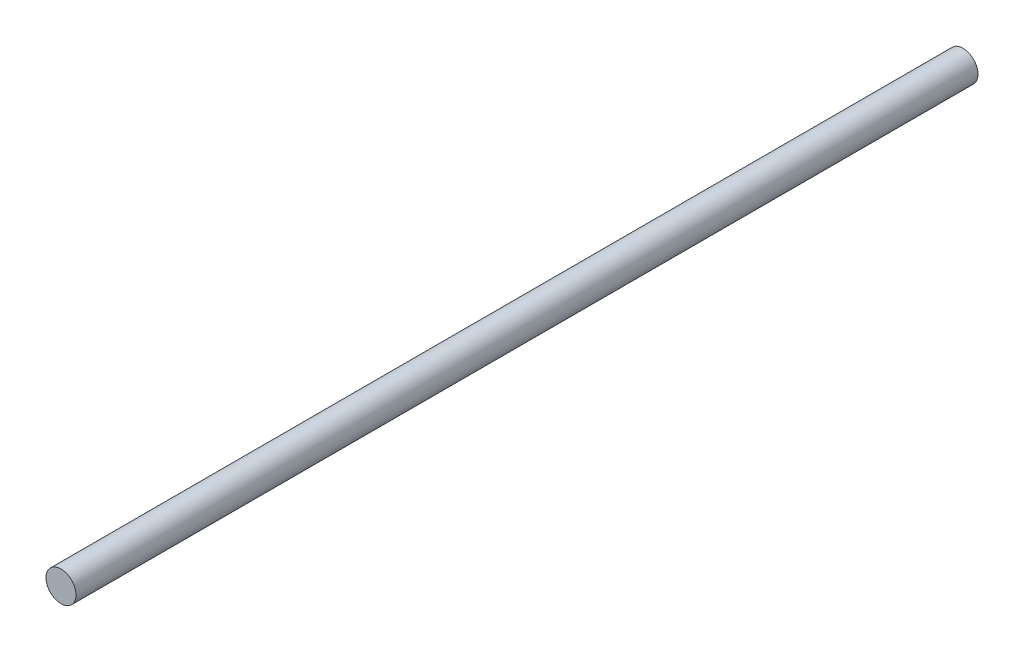
from build123d import *

# Parameters (mm, degrees)
SKETCH1_R           = 12.7
BOSS_EXTRUDE1_DEPTH = 762


with BuildPart() as part:
    # Sketch1 → Boss-Extrude1 (new body)
    with BuildSketch(Plane.XY):
        Circle(SKETCH1_R)
    extrude(amount=BOSS_EXTRUDE1_DEPTH)


solid = part.part
